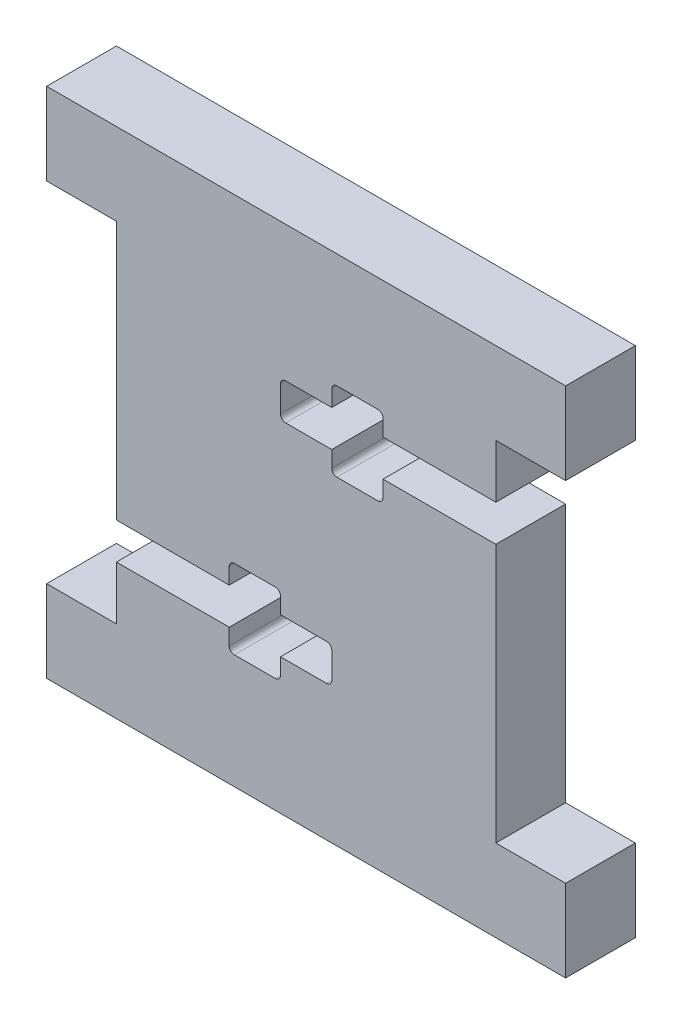
from build123d import *

# Parameters (mm, degrees)
SKETCH1_W           = 50.6
SKETCH1_H           = 50
BOSS_EXTRUDE1_DEPTH = 6.8
SKETCH2_W           = 6.8
SKETCH2_H           = 34
CUT_EXTRUDE1_DEPTH  = 6.8
SKETCH3_W           = 5
SKETCH3_H           = 3.55
SKETCH3_H_2         = 2.085
SKETCH3_W_2         = 11
CUT_EXTRUDE2_DEPTH  = 6.8
FILLET1_R           = 0.5


with BuildPart() as part:
    # Sketch1 → Boss-Extrude1 (new body)
    with BuildSketch(Plane.XY):
        Rectangle(SKETCH1_W, SKETCH1_H)
    extrude(amount=BOSS_EXTRUDE1_DEPTH)

    # Sketch2 → Cut-Extrude1 (cut)
    with BuildSketch(Plane.XY.offset(6.8)):
        with Locations((21.9, 0)):
            Rectangle(SKETCH2_W, SKETCH2_H)
    cut_extrude1 = extrude(amount=-CUT_EXTRUDE1_DEPTH, mode=Mode.SUBTRACT)

    # Mirror1: Cut-Extrude1 across plane
    add(cut_extrude1.mirror(Plane(origin=(0, 0, 0), x_dir=(0, 0, 1), z_dir=(1, 0, 0))), mode=Mode.SUBTRACT)

    # Sketch3 → Cut-Extrude2 (cut)
    with BuildSketch(Plane.XY.offset(6.8)):
        with Locations((0, -10)):
            Rectangle(SKETCH3_W, SKETCH3_H)
        with Locations((-5, -12.8175)):
            Rectangle(SKETCH3_W, SKETCH3_H_2)
        with Locations((-13, -10)):
            Rectangle(SKETCH3_W_2, SKETCH3_H)
        with Locations((-5, -7.1825)):
            Rectangle(SKETCH3_W, SKETCH3_H_2)
        with Locations((-5, -10)):
            Rectangle(SKETCH3_W, SKETCH3_H)
        with Locations((5, 10)):
            Rectangle(SKETCH3_W, SKETCH3_H)
        with Locations((0, 10)):
            Rectangle(SKETCH3_W, SKETCH3_H)
        with Locations((5, 7.1825)):
            Rectangle(SKETCH3_W, SKETCH3_H_2)
        with Locations((5, 12.8175)):
            Rectangle(SKETCH3_W, SKETCH3_H_2)
        with Locations((13, 10)):
            Rectangle(SKETCH3_W_2, SKETCH3_H)
    extrude(amount=-CUT_EXTRUDE2_DEPTH, mode=Mode.SUBTRACT)

    # Fillet1
    fillet1_edges = [part.edges().sort_by_distance(p)[0] for p in [
        (2.5, -8.225, 3.4),
        (2.5, -11.775, 3.4),
        (-2.5, -13.86, 3.4),
        (-7.5, -13.86, 3.4),
        (-7.5, -6.14, 3.4),
        (-2.5, -6.14, 3.4),
        (-2.5, 8.225, 3.4),
        (-2.5, 11.775, 3.4),
        (2.5, 13.86, 3.4),
        (7.5, 13.86, 3.4),
        (7.5, 6.14, 3.4),
        (2.5, 6.14, 3.4),
    ]]
    fillet(fillet1_edges, radius=FILLET1_R)


solid = part.part
